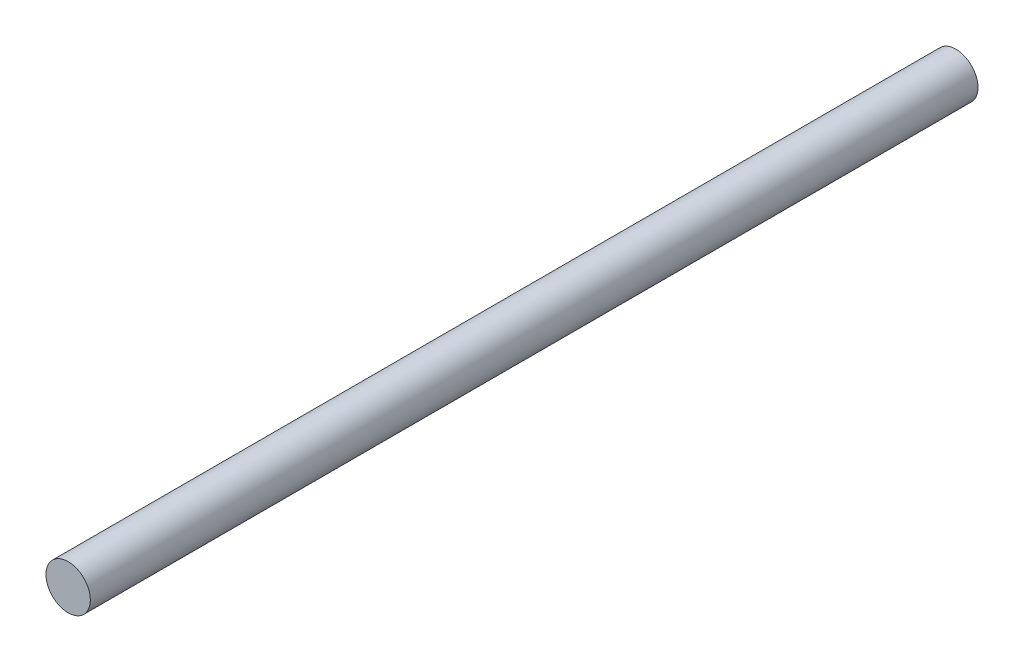
from build123d import *

# Parameters (mm, degrees)
SKETCH_1_R      = 2
EXTRUDE_1_DEPTH = 80


with BuildPart() as part:
    # 草图1 → 凸台-拉伸1 (new body)
    with BuildSketch(Plane.XY):
        Circle(SKETCH_1_R)
    extrude(amount=EXTRUDE_1_DEPTH)


solid = part.part
